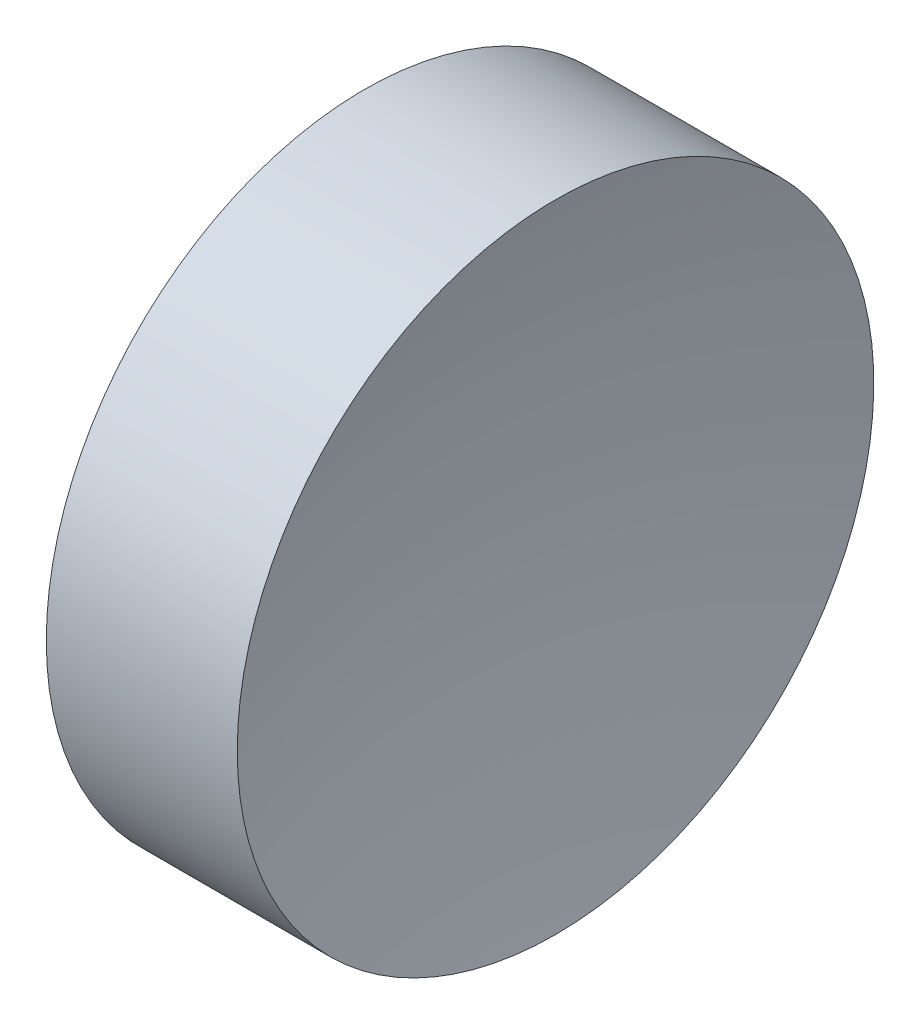
from build123d import *


with BuildPart() as part:
    # 草图1 → 旋转1 (revolve)
    with BuildSketch(Plane.XY, mode=Mode.PRIVATE) as revolve_1_sk:
        with BuildLine():
            Line((22.309268833, 13.031126091), (22.309268833, 16.181126091))
            Line((22.309268833, 16.181126091), (24.199460527, 16.181126091))
            ThreePointArc((24.199460527, 16.181126091), (23.907188103, 14.618163391), (23.809268833, 13.031126091))
            Line((23.809268833, 13.031126091), (22.309268833, 13.031126091))
        make_face()
    revolve(revolve_1_sk.sketch.rotate(Axis((20.684030635, 13.031126091, 0), (1, 0, 0)), 180), axis=Axis((20.684030635, 13.031126091, 0), (1, 0, 0)))  # turned: the seam where the file's is


solid = part.part
